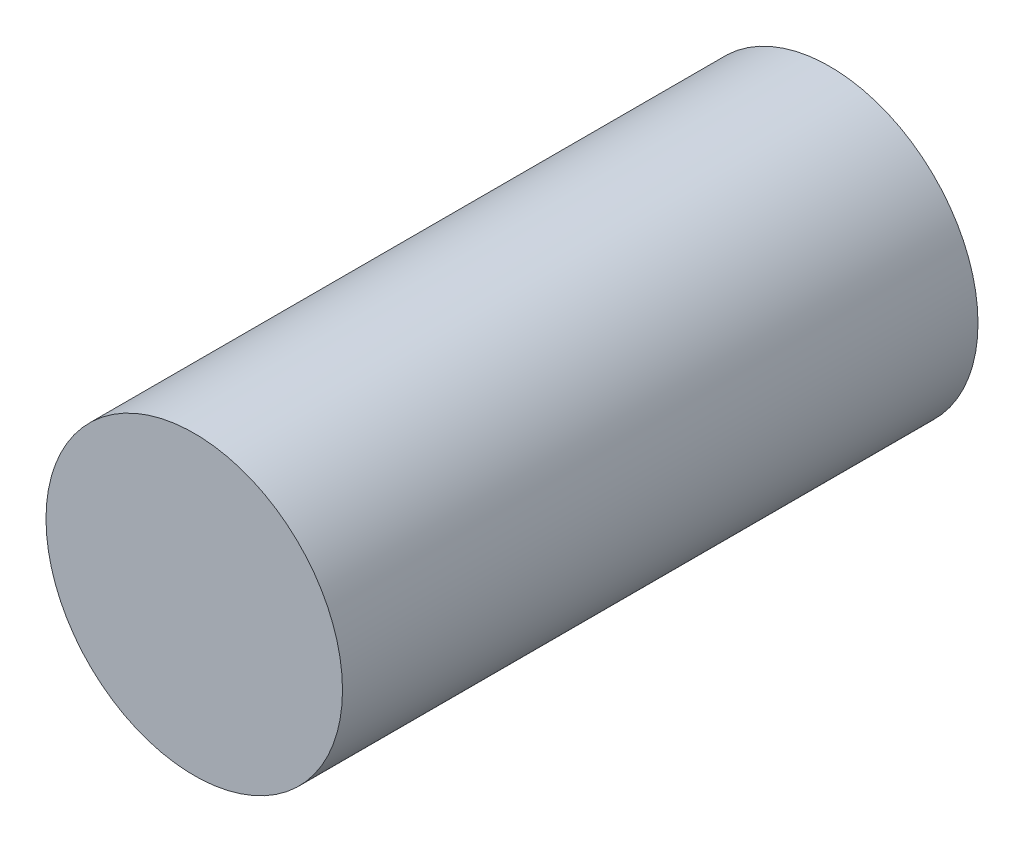
from build123d import *

# Parameters (mm, degrees)
SKETCH1_R           = 38.1
BOSS_EXTRUDE1_DEPTH = 163.322


with BuildPart() as part:
    # Sketch1 → Boss-Extrude1 (new body)
    with BuildSketch(Plane.XY):
        Circle(SKETCH1_R)
    extrude(amount=BOSS_EXTRUDE1_DEPTH)


solid = part.part
